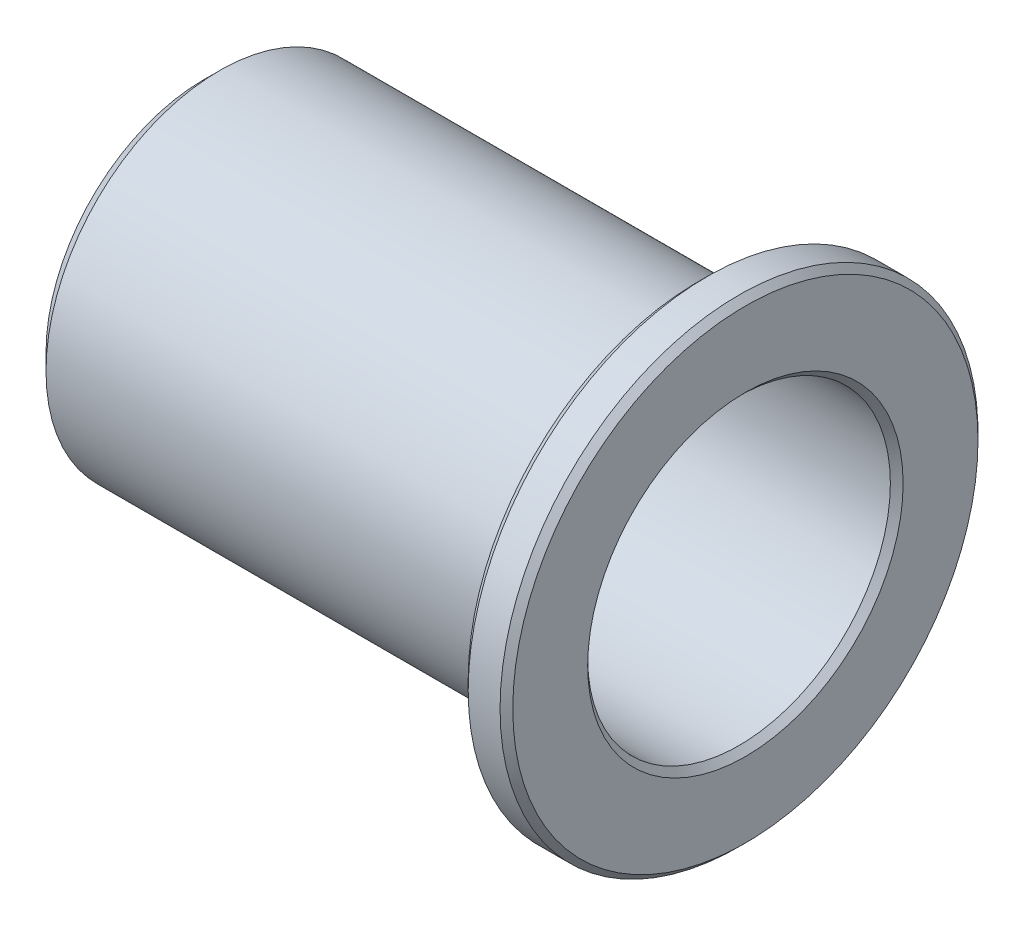
from build123d import *


with BuildPart() as part:
    # Эскиз1 → Повернуть2 (revolve)
    with BuildSketch(Plane.XY):
        Polygon((-31.14863846, 4.75), (-31.14863846, 4.95), (-30.64863846, 5.45), (-15.64863846, 5.45), (-15.64863846, 7.2), (-15.34863846, 7.5), (-14.34863846, 7.5), (-14.14863846, 7.3), (-14.14863846, 4.95), (-14.34863846, 4.75), align=None)
    revolve(axis=Axis((-38.482466054, 0, 0), (1, 0, 0)))


solid = part.part
